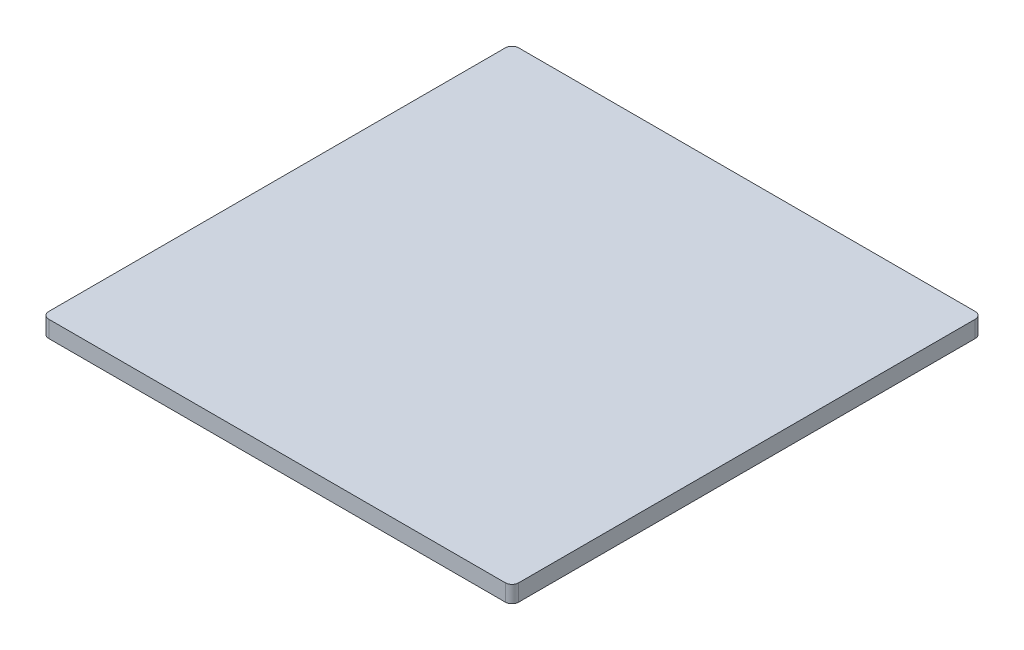
from build123d import *

# Parameters (mm, degrees)
BOSS_EXTRUDE1_DEPTH = 6.35


with BuildPart() as part:
    # Sketch2 → Boss-Extrude1 (new body)
    with BuildSketch(Plane(origin=(0, 0, 0), x_dir=(1, 0, 0), z_dir=(0, 1, 0))):
        with BuildLine():
            Line((-86.36, -88.9), (86.36, -88.9))
            ThreePointArc((86.36, -88.9), (88.156051224, -88.156051224), (88.9, -86.36))
            Line((88.9, -86.36), (88.9, 86.36))
            ThreePointArc((88.9, 86.36), (88.156051224, 88.156051224), (86.36, 88.9))
            Line((86.36, 88.9), (-86.36, 88.9))
            ThreePointArc((-86.36, 88.9), (-88.156051224, 88.156051224), (-88.9, 86.36))
            Line((-88.9, 86.36), (-88.9, -86.36))
            ThreePointArc((-88.9, -86.36), (-88.156051224, -88.156051224), (-86.36, -88.9))
        make_face()
    extrude(amount=BOSS_EXTRUDE1_DEPTH)


solid = part.part
